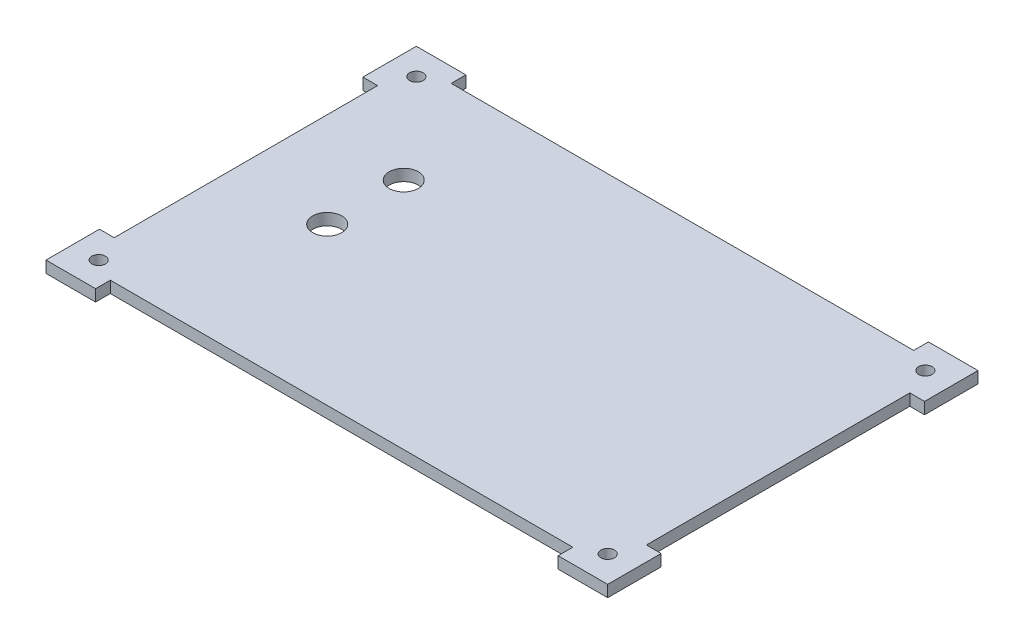
from build123d import *

# Parameters (mm, degrees)
SKETCH1_W           = 137.4
SKETCH1_H           = 88
BOSS_EXTRUDE1_DEPTH = 3
SKETCH2_R           = 1.75
CUT_EXTRUDE1_DEPTH  = 4
SKETCH3_W           = 9
SKETCH3_H           = 3.8
SKETCH3_W_2         = 3.8
SKETCH3_H_2         = 10
BOSS_EXTRUDE2_DEPTH = 3
SKETCH4_R           = 3.75
CUT_EXTRUDE2_DEPTH  = 4


with BuildPart() as part:
    # Sketch1 → Boss-Extrude1 (new body)
    with BuildSketch(Plane(origin=(0, 0, 0), x_dir=(1, 0, 0), z_dir=(0, 1, 0))):
        with Locations((68.7, -44)):
            Rectangle(SKETCH1_W, SKETCH1_H)
    extrude(amount=BOSS_EXTRUDE1_DEPTH)

    # Sketch2 → Cut-Extrude1 (cut, through all)
    with BuildSketch(Plane.XZ):
        with Locations((3, 85)):
            Circle(SKETCH2_R)
        with Locations((134.4, 85)):
            Circle(SKETCH2_R)
        with Locations((134.4, 3)):
            Circle(SKETCH2_R)
        with Locations((3, 3)):
            Circle(SKETCH2_R)
    extrude(amount=-CUT_EXTRUDE1_DEPTH, mode=Mode.SUBTRACT)

    # Sketch3 → Boss-Extrude2 (add, through all)
    with BuildSketch(Plane.XZ):
        Polygon((0, 91.8), (-3.8, 91.8), (-3.8, 78), (0, 78), (0, 88), align=None)
        with Locations((4.5, 89.9)):
            Rectangle(SKETCH3_W, SKETCH3_H)
        with Locations((-1.9, 5)):
            Rectangle(SKETCH3_W_2, SKETCH3_H_2)
        Polygon((9, 0), (0, 0), (-3.8, 0), (-3.8, -3.8), (9, -3.8), align=None)
        Polygon((137.4, 0), (128.4, 0), (128.4, -3.8), (141.2, -3.8), (141.2, 0), align=None)
        with Locations((139.3, 5)):
            Rectangle(SKETCH3_W_2, SKETCH3_H_2)
        with Locations((132.9, 89.9)):
            Rectangle(SKETCH3_W, SKETCH3_H)
        Polygon((137.4, 91.8), (137.4, 88), (137.4, 78), (141.2, 78), (141.2, 91.8), align=None)
    extrude(amount=-BOSS_EXTRUDE2_DEPTH)

    # Sketch4 → Cut-Extrude2 (cut, through all)
    with BuildSketch(Plane.XZ):
        with Locations((24.5, 47.5)):
            Circle(SKETCH4_R)
        with Locations((24.5, 27.75)):
            Circle(SKETCH4_R)
    extrude(amount=-CUT_EXTRUDE2_DEPTH, mode=Mode.SUBTRACT)


solid = part.part
